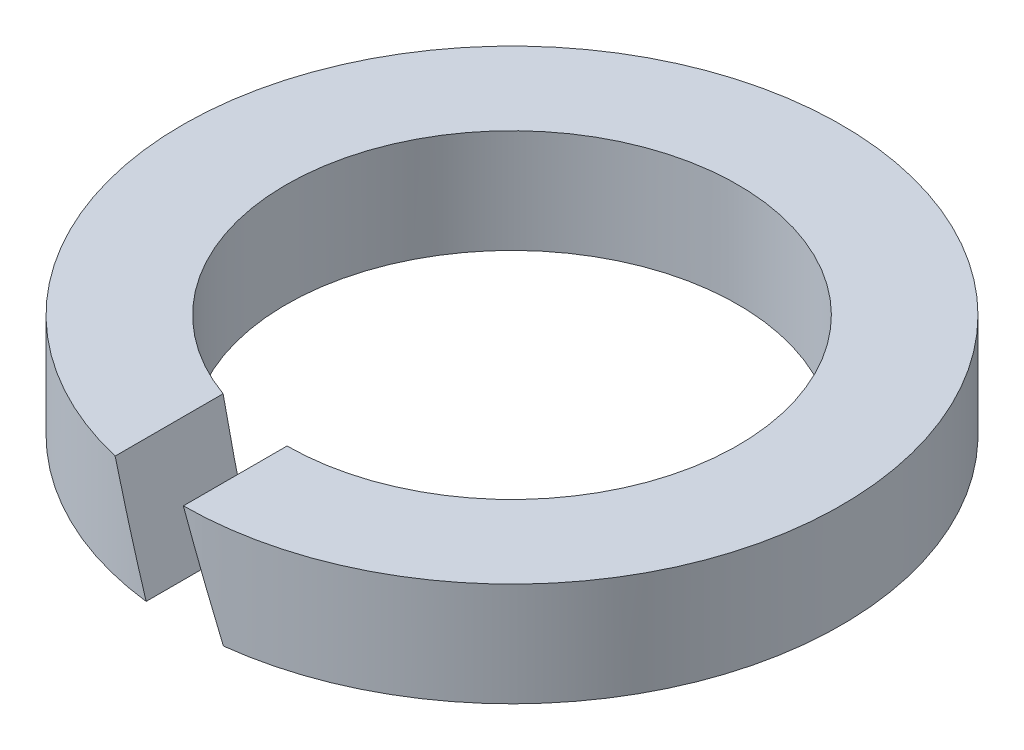
from build123d import *

# Parameters (mm, degrees)
SKE_W     = 1.4
SKE_H     = 1.4
CUT_REACH = 6.45


with BuildPart() as part:
    # Ske → Base (revolve)
    with BuildSketch(Plane.XY):
        with Locations((-3.75, 0.7)):
            Rectangle(SKE_W, SKE_H)
    revolve(axis=Axis((0, 15.759672306, 0), (0, -1, 0)))

    # Ske4 → Cut (cut, up to next)
    with BuildSketch(Plane.XY, mode=Mode.PRIVATE) as cut_sk1:
        Polygon((-0.521447109, 0), (0.521447109, 0), (0.011888781, 1.4), (-1.031005436, 1.4), align=None)
    cut_tool1 = extrude(cut_sk1.sketch, amount=CUT_REACH, mode=Mode.PRIVATE) & part.part
    add(cut_tool1.solids().sort_by_distance((-0.254779, 0.7, 0))[0], mode=Mode.SUBTRACT)


solid = part.part
